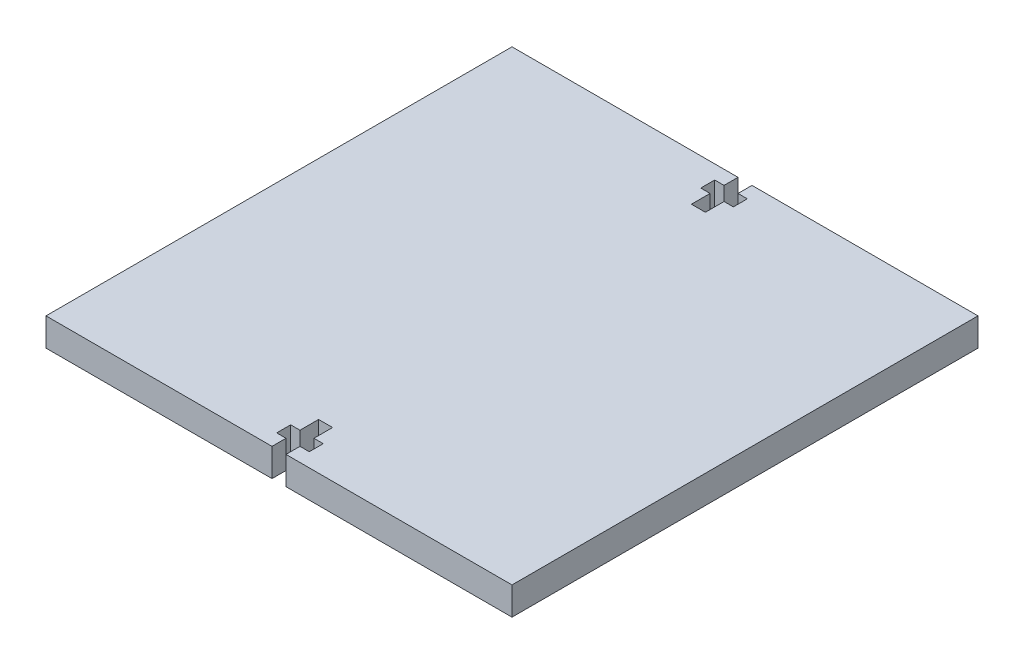
from build123d import *

# Parameters (mm, degrees)
SKETCH2_W           = 100
SKETCH2_H           = 100
BOSS_EXTRUDE1_DEPTH = 6
CUT_EXTRUDE1_DEPTH  = 7


with BuildPart() as part:
    # Sketch2 → Boss-Extrude1 (new body)
    with BuildSketch(Plane(origin=(0, 0, 0), x_dir=(1, 0, 0), z_dir=(0, 1, 0))):
        with Locations((-50, 50)):
            Rectangle(SKETCH2_W, SKETCH2_H)
    extrude(amount=BOSS_EXTRUDE1_DEPTH)

    # Sketch3 → Cut-Extrude1 (cut, through all)
    with BuildSketch(Plane(origin=(0, 6, 0), x_dir=(1, 0, 0), z_dir=(0, 1, 0))):
        Polygon((-50, 100), (-48.5, 100), (-48.5, 97), (-46.5, 97), (-46.5, 94), (-48.5, 94), (-48.5, 90), (-50, 90), (-51.5, 90), (-51.5, 94), (-53.5, 94), (-53.5, 97), (-51.5, 97), (-51.5, 100), align=None)
        Polygon((-50, 0), (-48.5, 0), (-48.5, 3), (-46.5, 3), (-46.5, 6), (-48.5, 6), (-48.5, 10), (-50, 10), (-51.5, 10), (-51.5, 6), (-53.5, 6), (-53.5, 3), (-51.5, 3), (-51.5, 0), align=None)
    extrude(amount=-CUT_EXTRUDE1_DEPTH, mode=Mode.SUBTRACT)


solid = part.part
